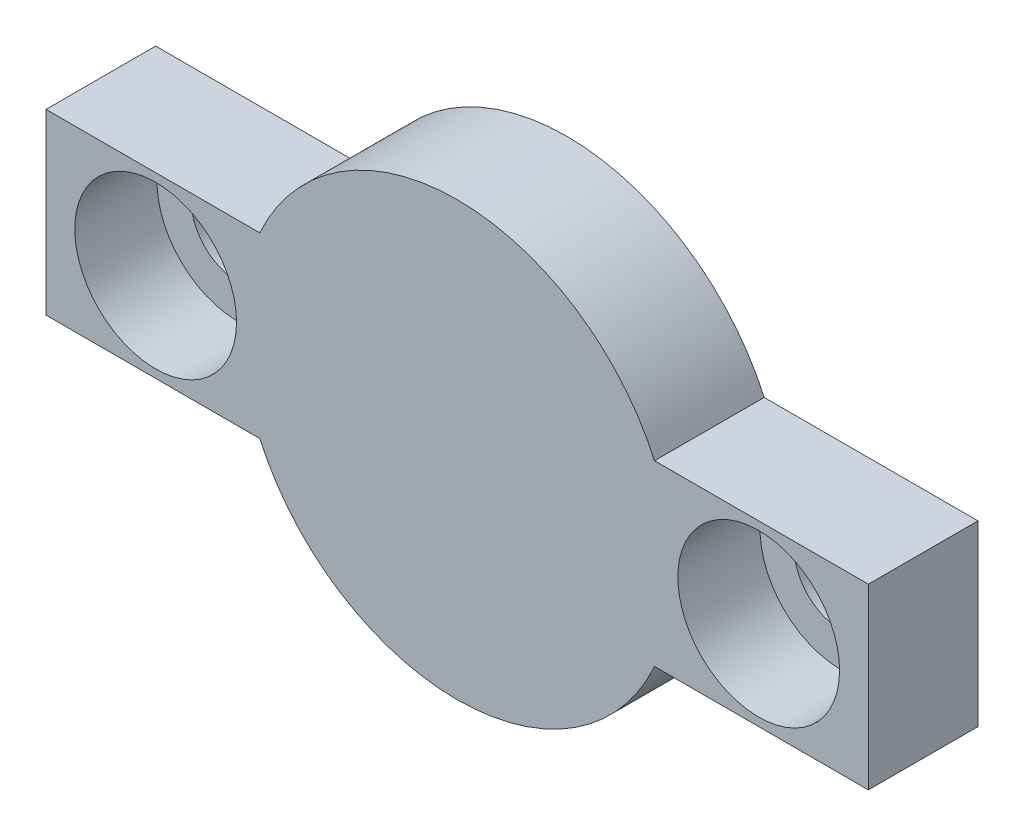
from build123d import *

# Parameters (mm, degrees)
SALIENTE_EXTRUIR1_DEPTH = 4
CROQUIS2_R              = 1.7
CORTAR_EXTRUIR1_DEPTH   = 4
CROQUIS3_R              = 2.95
CORTAR_EXTRUIR2_DEPTH   = 3


with BuildPart() as part:
    # Croquis1 → Saliente-Extruir1 (new body)
    with BuildSketch(Plane.XY):
        with BuildLine():
            Line((-7.200520814, -3.25), (-15, -3.25))
            Line((-15, -3.25), (-15, 3.25))
            Line((-15, 3.25), (-7.200520814, 3.25))
            ThreePointArc((-7.200520814, 3.25), (0, 7.9), (7.200520814, 3.25))
            Line((7.200520814, 3.25), (15, 3.25))
            Line((15, 3.25), (15, -3.25))
            Line((15, -3.25), (7.200520814, -3.25))
            ThreePointArc((7.200520814, -3.25), (0, -7.9), (-7.200520814, -3.25))
        make_face()
    extrude(amount=SALIENTE_EXTRUIR1_DEPTH)

    # Croquis2 → Cortar-Extruir1 (cut)
    with BuildSketch(Plane.XY.offset(4)):
        with Locations((-11, 0)):
            Circle(CROQUIS2_R)
        with Locations((11, 0)):
            Circle(CROQUIS2_R)
    extrude(amount=-CORTAR_EXTRUIR1_DEPTH, mode=Mode.SUBTRACT)

    # Croquis3 → Cortar-Extruir2 (cut)
    with BuildSketch(Plane.XY.offset(4)):
        with Locations((-11, 0)):
            Circle(CROQUIS3_R)
        with Locations((11, 0)):
            Circle(CROQUIS3_R)
    extrude(amount=-CORTAR_EXTRUIR2_DEPTH, mode=Mode.SUBTRACT)


solid = part.part
